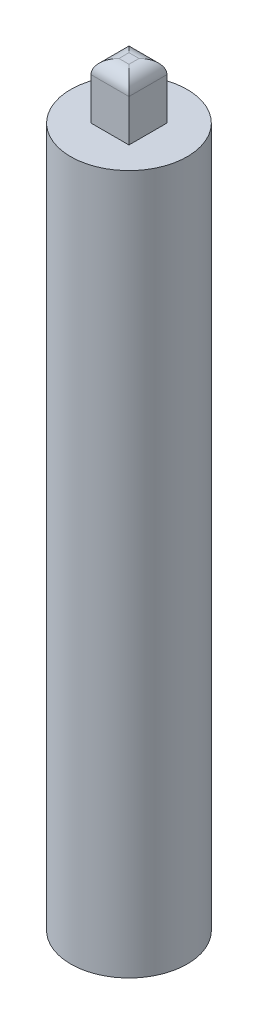
from build123d import *

# Parameters (mm, degrees)
SKETCH1_R           = 12.5
BOSS_EXTRUDE1_DEPTH = 150
SKETCH2_W           = 8.15
SKETCH2_H           = 8.15
BOSS_EXTRUDE2_DEPTH = 12
FILLET1_R           = 3
SKETCH3_W           = 8.2
SKETCH3_H           = 8.2
CUT_EXTRUDE1_DEPTH  = 20


with BuildPart() as part:
    # Sketch1 → Boss-Extrude1 (new body)
    with BuildSketch(Plane(origin=(0, 0, 0), x_dir=(1, 0, 0), z_dir=(0, 1, 0))):
        Circle(SKETCH1_R)
    extrude(amount=BOSS_EXTRUDE1_DEPTH)

    # Sketch2 → Boss-Extrude2 (add)
    with BuildSketch(Plane(origin=(0, 150, 0), x_dir=(1, 0, 0), z_dir=(0, 1, 0))):
        Rectangle(SKETCH2_W, SKETCH2_H)
    extrude(amount=BOSS_EXTRUDE2_DEPTH)

    # Fillet1
    fillet1_edges = [part.edges().sort_by_distance(p)[0] for p in [
        (4.075, 162, 0),
        (0, 162, -4.075),
        (-4.075, 162, 0),
        (0, 162, 4.075),
    ]]
    fillet(fillet1_edges, radius=FILLET1_R)

    # Sketch3 → Cut-Extrude1 (cut)
    with BuildSketch(Plane.XZ):
        Rectangle(SKETCH3_W, SKETCH3_H)
    extrude(amount=-CUT_EXTRUDE1_DEPTH, mode=Mode.SUBTRACT)


solid = part.part
